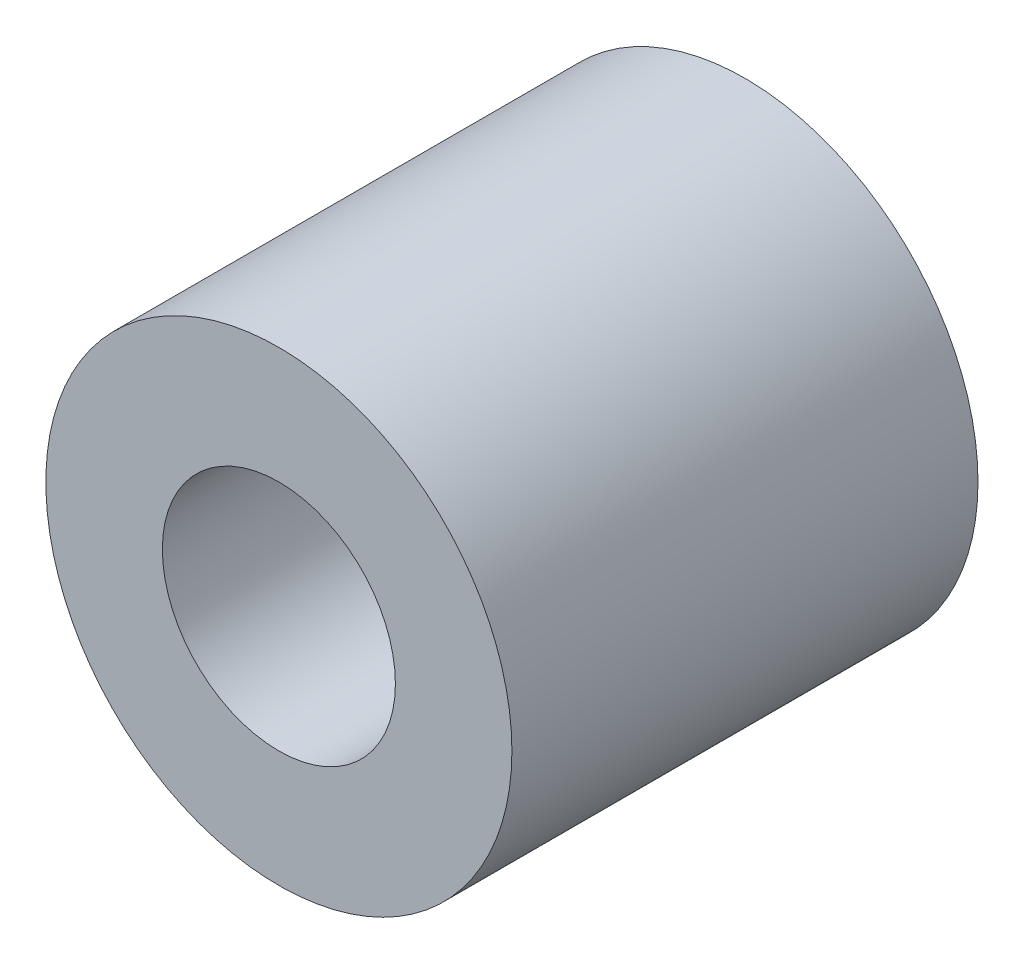
from build123d import *

# Parameters (mm, degrees)
SZKIC1_R                    = 2.5
DODANIE_WYCI_GNI_CIE1_DEPTH = 5
OTW_R_GWINTOWANY_M31_D      = 2.5


with BuildPart() as part:
    # Szkic1 → Dodanie-wyciągnięcie1 (new body)
    with BuildSketch(Plane.XY):
        Circle(SZKIC1_R)
    extrude(amount=DODANIE_WYCI_GNI_CIE1_DEPTH)

    # Otwór gwintowany M31 (through all)
    with Locations(Plane.XY.offset(5)):
        with Locations((0, 0)):
            Hole(OTW_R_GWINTOWANY_M31_D / 2)


solid = part.part
